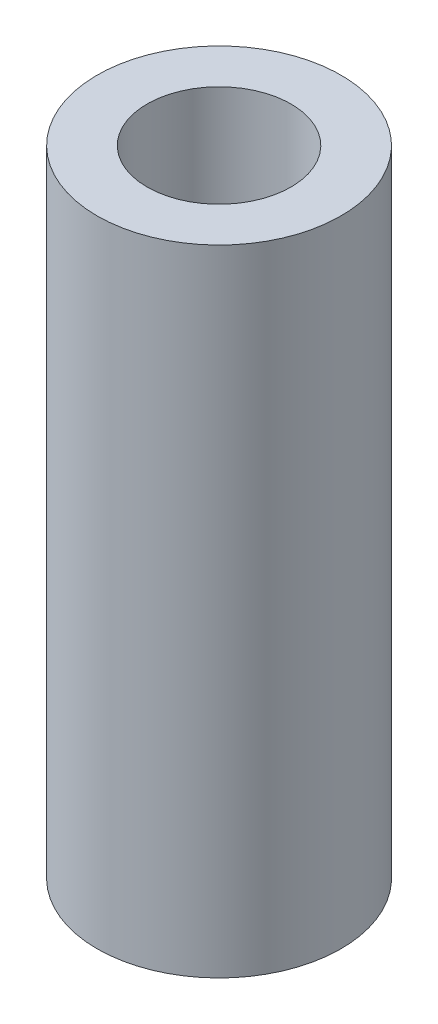
from build123d import *

# Parameters (mm, degrees)
SKETCH1_R           = 6.1
SKETCH1_R_2         = 3.6
BOSS_EXTRUDE1_DEPTH = 31.75


with BuildPart() as part:
    # Sketch1 → Boss-Extrude1 (new body)
    with BuildSketch(Plane(origin=(0, 0, 0), x_dir=(1, 0, 0), z_dir=(0, 1, 0))):
        Circle(SKETCH1_R)
        Circle(SKETCH1_R_2, mode=Mode.SUBTRACT)
    extrude(amount=BOSS_EXTRUDE1_DEPTH)


solid = part.part
